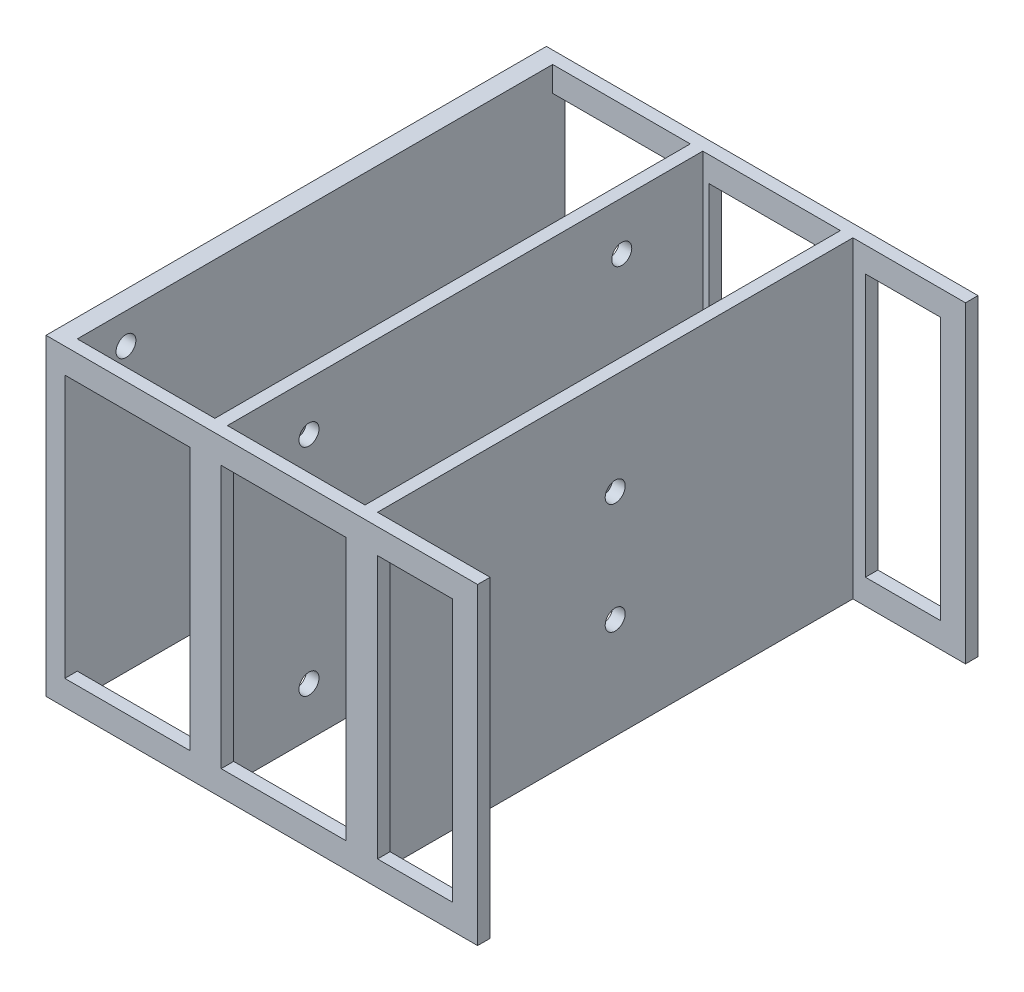
from build123d import *

# Parameters (mm, degrees)
SKETCH_1_W          = 22
SKETCH_1_H          = 76
EXTRUDE_1_DEPTH     = 50
SKETCH_5_W          = 20
SKETCH_5_H          = 42
SKETCH_5_W_2        = 12
CUT_EXTRUDE_1_DEPTH = 10
SKETCH_2_R          = 1.6
CUT_EXTRUDE_2_DEPTH = 10
SKETCH_3_R          = 1.6
CUT_EXTRUDE_3_DEPTH = 10
SKETCH_4_R          = 1.587
CUT_EXTRUDE_4_DEPTH = 10


with BuildPart() as part:
    # 草图1 → 凸台-拉伸1 (new body)
    with BuildSketch(Plane(origin=(0, 0, 0), x_dir=(1, 0, 0), z_dir=(0, 1, 0))):
        Polygon((0, 0), (69, 0), (69, 2), (51, 2), (51, 78), (69, 78), (69, 80), (0, 80), align=None)
        with Locations((14, 40)):
            Rectangle(SKETCH_1_W, SKETCH_1_H, mode=Mode.SUBTRACT)
        with Locations((38, 40)):
            Rectangle(SKETCH_1_W, SKETCH_1_H, mode=Mode.SUBTRACT)
    extrude(amount=EXTRUDE_1_DEPTH)

    # 草图5 → 切除-拉伸1 (cut)
    with BuildSketch(Plane.XY):
        with Locations((13, 25)):
            Rectangle(SKETCH_5_W, SKETCH_5_H)
        with Locations((38, 25)):
            Rectangle(SKETCH_5_W, SKETCH_5_H)
        with Locations((59, 25)):
            Rectangle(SKETCH_5_W_2, SKETCH_5_H)
    cut_extrude_1 = extrude(amount=-CUT_EXTRUDE_1_DEPTH, mode=Mode.SUBTRACT)

    # 镜向1: 切除-拉伸1 across plane
    add(cut_extrude_1.mirror(Plane.XY.offset(-40)), mode=Mode.SUBTRACT)

    # 草图2 → 切除-拉伸2 (cut)
    with BuildSketch(Plane(origin=(51, 0, 0), x_dir=(0, 0, -1), z_dir=(1, 0, 0))):
        with Locations((40, 33.85)):
            Circle(SKETCH_2_R)
        with Locations((40, 16.15)):
            Circle(SKETCH_2_R)
    extrude(amount=-CUT_EXTRUDE_2_DEPTH, mode=Mode.SUBTRACT)

    # 草图3 → 切除-拉伸3 (cut)
    with BuildSketch(Plane(origin=(27, 0, 0), x_dir=(0, 0, -1), z_dir=(1, 0, 0))):
        with Locations((15.046260159, 7.75)):
            Circle(SKETCH_3_R)
        with Locations((65.046260159, 7.75)):
            Circle(SKETCH_3_R)
        with Locations((15.046260159, 42.25)):
            Circle(SKETCH_3_R)
        with Locations((65.046260159, 42.25)):
            Circle(SKETCH_3_R)
    extrude(amount=-CUT_EXTRUDE_3_DEPTH, mode=Mode.SUBTRACT)

    # 草图4 → 切除-拉伸4 (cut)
    with BuildSketch(Plane(origin=(3, 0, 0), x_dir=(0, 0, -1), z_dir=(1, 0, 0))):
        with Locations((69.78201983, 5.121000004)):
            Circle(SKETCH_4_R)
        with Locations((9.78201983, 45.121000004)):
            Circle(SKETCH_4_R)
    extrude(amount=-CUT_EXTRUDE_4_DEPTH, mode=Mode.SUBTRACT)


solid = part.part
